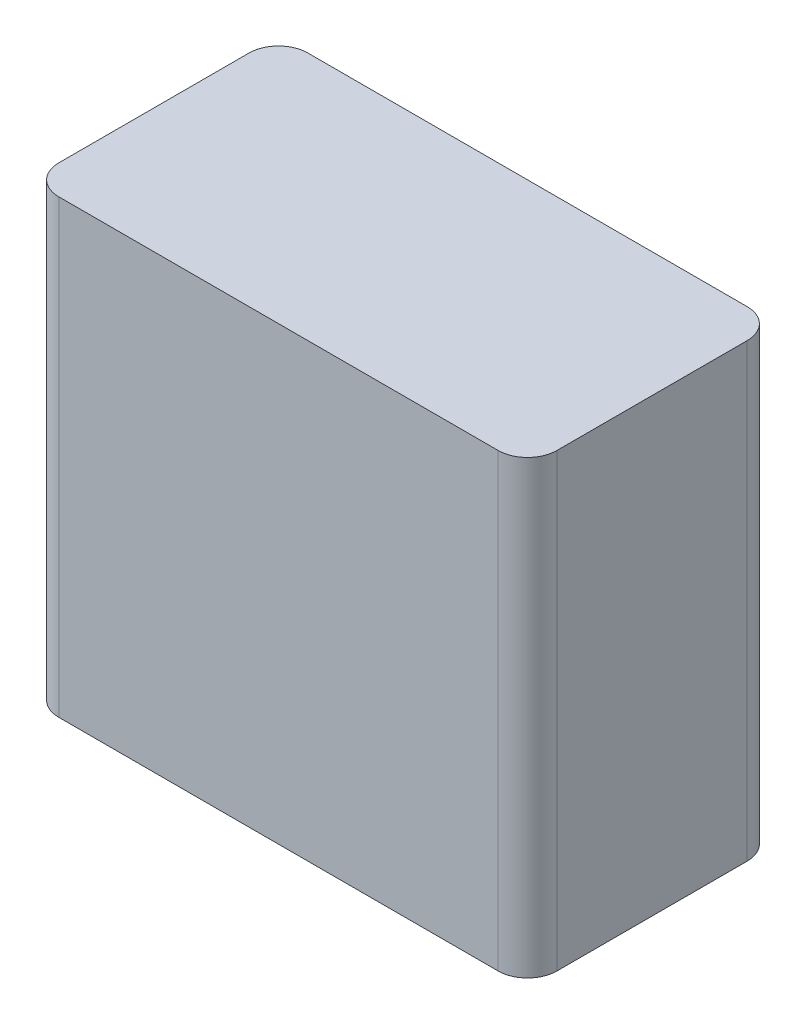
from build123d import *

# Parameters (mm, degrees)
SKETCH1_W           = 40
SKETCH1_H           = 20
BOSS_EXTRUDE1_DEPTH = 36.2
FILLET1_R           = 2.36


with BuildPart() as part:
    # Sketch1 → Boss-Extrude1 (new body)
    with BuildSketch(Plane(origin=(0, 0, 0), x_dir=(1, 0, 0), z_dir=(0, 1, 0))):
        Rectangle(SKETCH1_W, SKETCH1_H)
    extrude(amount=BOSS_EXTRUDE1_DEPTH)

    # Fillet1
    fillet1_edges = [part.edges().sort_by_distance(p)[0] for p in [
        (-20, 18.1, -10),
        (20, 18.1, -10),
        (20, 18.1, 10),
        (-20, 18.1, 10),
    ]]
    fillet(fillet1_edges, radius=FILLET1_R)


solid = part.part
